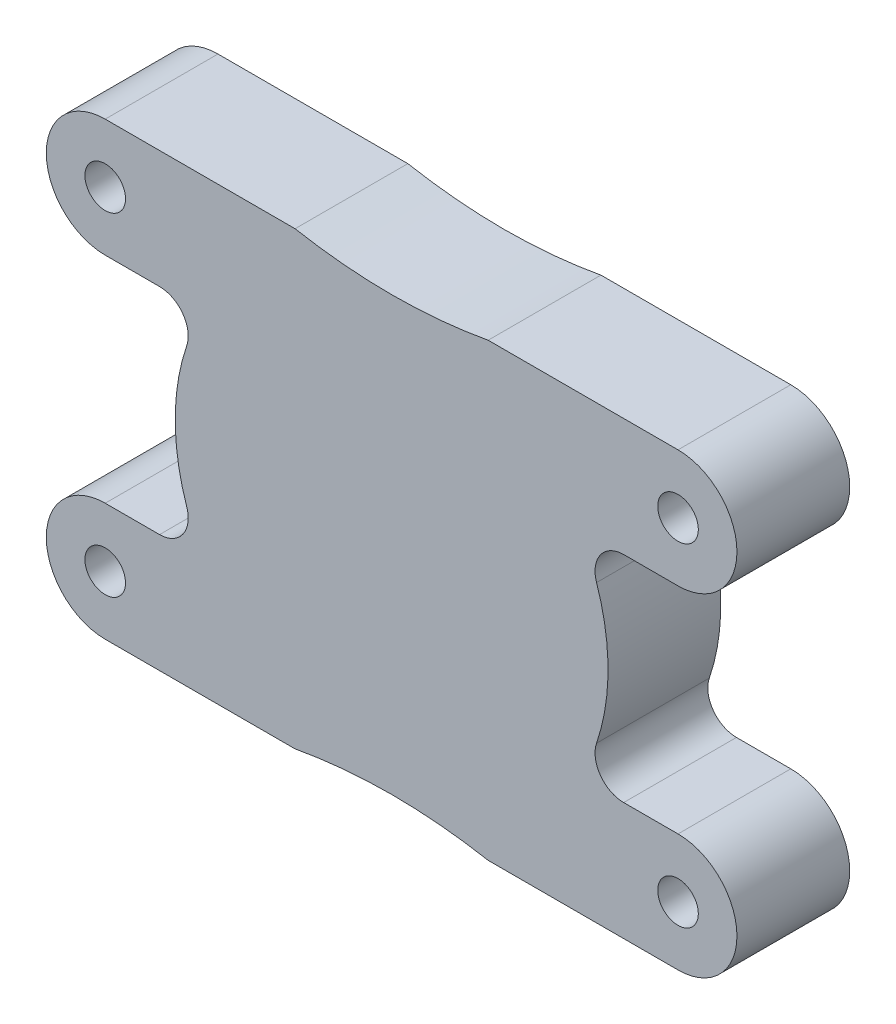
from build123d import *

# Parameters (mm, degrees)
SKETCH1_R           = 1.8
BOSS_EXTRUDE1_DEPTH = 10


with BuildPart() as part:
    # Sketch1 → Boss-Extrude1 (new body)
    with BuildSketch(Plane.XY):
        with BuildLine():
            Line((8.562572408, -19.9749896), (25.4, -19.9749896))
            ThreePointArc((25.4, -19.9749896), (30.6249948, -14.7499948), (25.4, -9.525))
            Line((25.4, -9.525), (20.579786947, -9.525))
            ThreePointArc((20.579786947, -9.525), (18.515185258, -8.464533666), (18.174552534, -6.168637692))
            ThreePointArc((18.174552534, -6.168637692), (19.192875, 0), (18.174552534, 6.168637692))
            ThreePointArc((18.174552534, 6.168637692), (18.515185258, 8.464533666), (20.579786947, 9.525))
            Line((20.579786947, 9.525), (25.4, 9.525))
            ThreePointArc((25.4, 9.525), (30.6249948, 14.7499948), (25.4, 19.9749896))
            Line((25.4, 19.9749896), (8.562572408, 19.9749896))
            ThreePointArc((8.562572408, 19.9749896), (0, 19.192875), (-8.562572408, 19.9749896))
            Line((-8.562572408, 19.9749896), (-25.4, 19.9749896))
            ThreePointArc((-25.4, 19.9749896), (-30.6249948, 14.7499948), (-25.4, 9.525))
            Line((-25.4, 9.525), (-20.579786947, 9.525))
            ThreePointArc((-20.579786947, 9.525), (-18.515185258, 8.464533666), (-18.174552534, 6.168637692))
            ThreePointArc((-18.174552534, 6.168637692), (-19.192875, 0), (-18.174552534, -6.168637692))
            ThreePointArc((-18.174552534, -6.168637692), (-18.515185258, -8.464533666), (-20.579786947, -9.525))
            Line((-20.579786947, -9.525), (-25.4, -9.525))
            ThreePointArc((-25.4, -9.525), (-30.6249948, -14.7499948), (-25.4, -19.9749896))
            Line((-25.4, -19.9749896), (-8.562572408, -19.9749896))
            ThreePointArc((-8.562572408, -19.9749896), (0, -19.192875), (8.562572408, -19.9749896))
        make_face()
        with Locations((-25.4, 14.7499948)):
            Circle(SKETCH1_R, mode=Mode.SUBTRACT)
        with Locations((-25.4, -14.7499948)):
            Circle(SKETCH1_R, mode=Mode.SUBTRACT)
        with Locations((25.4, -14.7499948)):
            Circle(SKETCH1_R, mode=Mode.SUBTRACT)
        with Locations((25.4, 14.7499948)):
            Circle(SKETCH1_R, mode=Mode.SUBTRACT)
    extrude(amount=BOSS_EXTRUDE1_DEPTH)


solid = part.part
